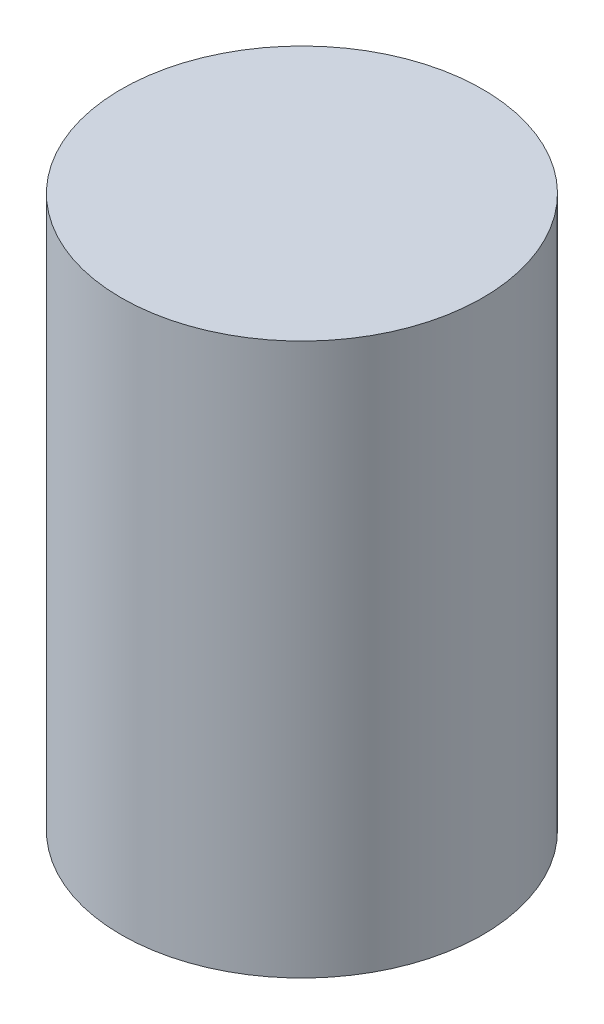
from build123d import *

# Parameters (mm, degrees)
SKETCH1_R           = 1.9
BOSS_EXTRUDE2_DEPTH = 5.8


with BuildPart() as part:
    # Sketch1 → Boss-Extrude2 (new body)
    with BuildSketch(Plane(origin=(0, 0, 0), x_dir=(1, 0, 0), z_dir=(0, 1, 0))):
        Circle(SKETCH1_R)
    extrude(amount=BOSS_EXTRUDE2_DEPTH)


solid = part.part
